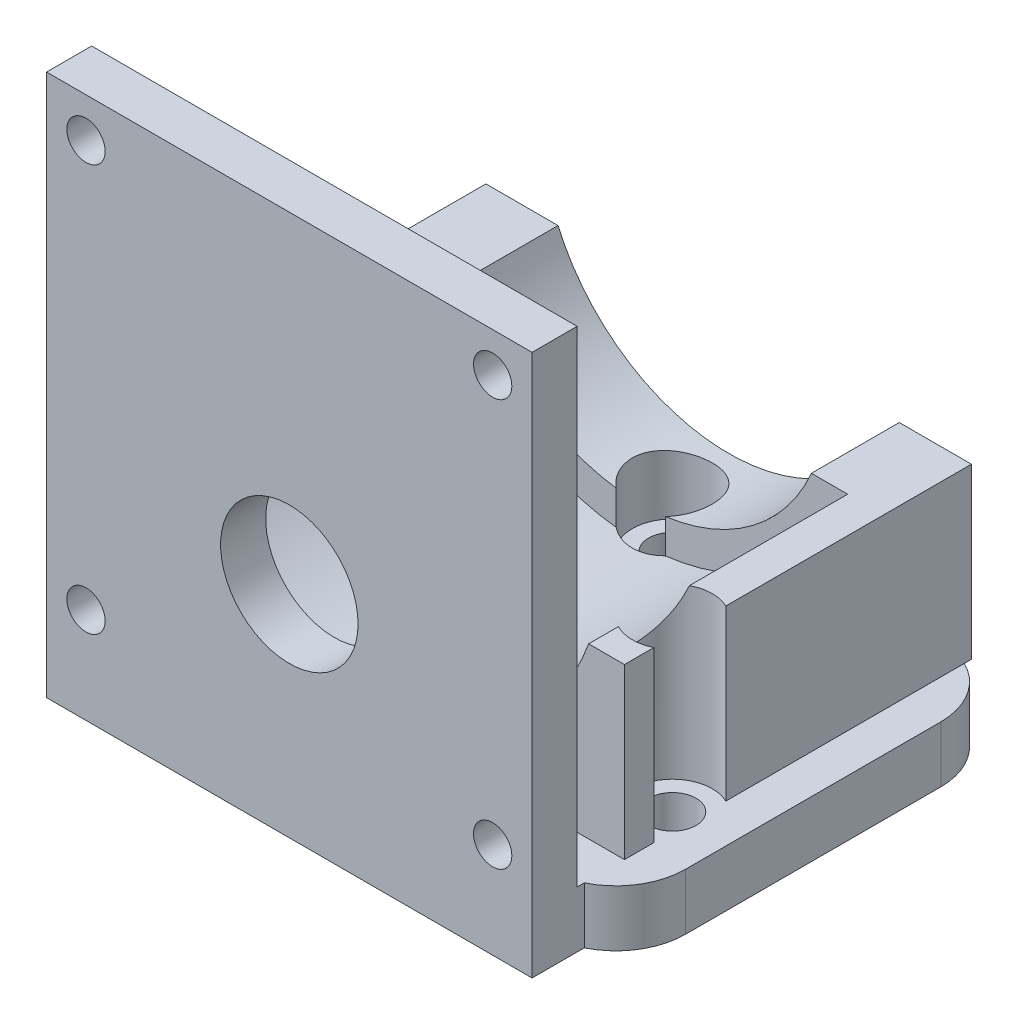
from build123d import *

# Parameters (mm, degrees)
SKETCH_1_W          = 30
SKETCH_1_H          = 30
EXTRUDE_1_DEPTH     = 5
SKETCH_2_W          = 30
SKETCH_2_H          = 5
EXTRUDE_2_DEPTH     = 10
SKETCH_3_R          = 2.1
CUT_EXTRUDE_1_DEPTH = 5
EXTRUDE_3_DEPTH     = 20
SKETCH_5_W          = 35
SKETCH_5_H          = 5
EXTRUDE_4_DEPTH     = 10
SKETCH_6_W          = 35
SKETCH_6_H          = 5
EXTRUDE_5_DEPTH     = 10
SKETCH_7_R          = 2.1
CUT_EXTRUDE_2_DEPTH = 10
FILLET_1_R          = 6.17
FILLET_2_R          = 6.17
SKETCH_8_W          = 43.093455854
SKETCH_8_H          = 31.755969384
CUT_EXTRUDE_3_DEPTH = 25
SKETCH_9_W          = 43.1
SKETCH_9_H          = 43.1
SKETCH_9_R          = 6.1
SKETCH_9_R_2        = 1.7
EXTRUDE_6_DEPTH     = 4
EXTRUDE_7_DEPTH     = 23
EXTRUDE_8_DEPTH     = 7.8
CUT_EXTRUDE_START   = -35
SKETCH_12_W         = 51.858978503
SKETCH_12_H         = 9.121001398
CUT_EXTRUDE_4_DEPTH = 35
SKETCH_14_W         = 43.1
SKETCH_14_H         = 5
EXTRUDE_9_DEPTH     = 8.2
SKETCH_15_R         = 2.1
CUT_EXTRUDE_5_DEPTH = 49.1
SKETCH_16_R         = 3.55
CUT_EXTRUDE_6_DEPTH = 44.1


with BuildPart() as part:
    # 스케치1 → 보스-돌출1 (new body)
    with BuildSketch(Plane.XY):
        Rectangle(SKETCH_1_W, SKETCH_1_H)
    extrude(amount=EXTRUDE_1_DEPTH)

    # 스케치2 → 보스-돌출2 (add)
    with BuildSketch(Plane(origin=(0, 0, 0), x_dir=(-1, 0, 0), z_dir=(0, 0, -1))):
        with Locations((0, -12.5)):
            Rectangle(SKETCH_2_W, SKETCH_2_H)
    extrude(amount=EXTRUDE_2_DEPTH)

    # 스케치3 → 컷-돌출1 (cut)
    with BuildSketch(Plane(origin=(0, -10, 0), x_dir=(1, 0, 0), z_dir=(0, 1, 0))):
        with Locations((0, 5)):
            Circle(SKETCH_3_R)
    extrude(amount=-CUT_EXTRUDE_1_DEPTH, mode=Mode.SUBTRACT)

    # 스케치4 → 보스-돌출3 (add)
    with BuildSketch(Plane.XY.offset(5)):
        Polygon((10.2, -15), (15, -15), (15, 15), (-15, 15), (-15, -15), (-10.2, -15), (-10.2, -18.997175384), (10.2, -18.997175384), align=None)
    extrude(amount=EXTRUDE_3_DEPTH)

    # 스케치5 → 보스-돌출4 (add)
    with BuildSketch(Plane.ZY.offset(15)):
        with Locations((7.5, -12.5)):
            Rectangle(SKETCH_5_W, SKETCH_5_H)
    extrude(amount=EXTRUDE_4_DEPTH)

    # 스케치6 → 보스-돌출5 (add)
    with BuildSketch(Plane(origin=(15, 0, 0), x_dir=(0, 0, -1), z_dir=(1, 0, 0))):
        with Locations((-7.5, -12.5)):
            Rectangle(SKETCH_6_W, SKETCH_6_H)
    extrude(amount=EXTRUDE_5_DEPTH)

    # 스케치7 → 컷-돌출2 (cut)
    with BuildSketch(Plane(origin=(0, -10, 0), x_dir=(1, 0, 0), z_dir=(0, 1, 0))):
        with Locations((-20, -15)):
            Circle(SKETCH_7_R)
        with Locations((20, -15)):
            Circle(SKETCH_7_R)
    extrude(amount=-CUT_EXTRUDE_2_DEPTH, mode=Mode.SUBTRACT)

    # 필렛1
    fillet_1_edges = [part.edges().sort_by_distance(p)[0] for p in [
        (25, -12.5, 25),
    ]]
    fillet(fillet_1_edges, radius=FILLET_1_R)

    # 필렛2
    fillet_2_edges = [part.edges().sort_by_distance(p)[0] for p in [
        (25, -12.5, -10),
    ]]
    fillet(fillet_2_edges, radius=FILLET_2_R)

    # 스케치8 → 컷-돌출3 (cut)
    with BuildSketch(Plane(origin=(0, 15, 0), x_dir=(1, 0, 0), z_dir=(0, 1, 0))):
        with Locations((-0.577881592, -10.851708682)):
            Rectangle(SKETCH_8_W, SKETCH_8_H)
    extrude(amount=-CUT_EXTRUDE_3_DEPTH, mode=Mode.SUBTRACT)

    # 스케치12 → 컷-돌출4 (cut)
    with BuildSketch(Plane.XY.offset(25).offset(CUT_EXTRUDE_START)):
        with Locations((0.929489252, -19.560500699)):
            Rectangle(SKETCH_12_W, SKETCH_12_H)
    extrude(amount=CUT_EXTRUDE_4_DEPTH, mode=Mode.SUBTRACT)



with BuildPart() as body_2:
    # 스케치9 → 보스-돌출6 (new body)
    with BuildSketch(Plane.XY.offset(29)):
        with Locations((0, 11.55)):
            Rectangle(SKETCH_9_W, SKETCH_9_H)
        with Locations((0, 4.5)):
            Circle(SKETCH_9_R, mode=Mode.SUBTRACT)
        with Locations((18.05, 29.6)):
            Circle(SKETCH_9_R_2, mode=Mode.SUBTRACT)
        with Locations((18.05, -6.5)):
            Circle(SKETCH_9_R_2, mode=Mode.SUBTRACT)
        with Locations((-18.05, -6.5)):
            Circle(SKETCH_9_R_2, mode=Mode.SUBTRACT)
        with Locations((-18.05, 29.6)):
            Circle(SKETCH_9_R_2, mode=Mode.SUBTRACT)
    extrude(amount=-EXTRUDE_6_DEPTH)


with BuildPart() as body_3:
    # 스케치10 → 보스-돌출7 (new body)
    with BuildSketch(Plane(origin=(0, 0, 20.8), x_dir=(-1, 0, 0), z_dir=(0, 0, -1))):
        with BuildLine():
            Line((-21.55, 5), (-18.367022078, 5))
            ThreePointArc((-18.367022078, 5), (0, -7.95), (18.367022078, 5))
            Line((18.367022078, 5), (21.55, 5))
            Line((21.55, 5), (21.55, -10))
            Line((21.55, -10), (-21.55, -10))
            Line((-21.55, -10), (-21.55, 5))
        make_face()
    extrude(amount=EXTRUDE_7_DEPTH)

    # 스케치11 → 보스-돌출8 (add)
    with BuildSketch(Plane(origin=(0, 0, -2.2), x_dir=(-1, 0, 0), z_dir=(0, 0, -1))):
        with BuildLine():
            Line((-21.55, 5), (-15.144223321, 5))
            ThreePointArc((-15.144223321, 5), (0, -4.95), (15.144223321, 5))
            Line((15.144223321, 5), (21.55, 5))
            Line((21.55, 5), (21.55, -10))
            Line((21.55, -10), (-21.55, -10))
            Line((-21.55, -10), (-21.55, 5))
        make_face()
    extrude(amount=EXTRUDE_8_DEPTH)


with BuildPart() as part_1:
    add(part.part)

    add(body_2.part)  # 보스-돌출9 merges body 2

    add(body_3.part)  # 보스-돌출9 merges body 3
    # 스케치14 → 보스-돌출9 (add)
    with BuildSketch(Plane.XY.offset(29)):
        with Locations((0, -12.5)):
            Rectangle(SKETCH_14_W, SKETCH_14_H)
    extrude(amount=-EXTRUDE_9_DEPTH)

    # 스케치15 → 컷-돌출5 (cut, through all)
    with BuildSketch(Plane.XZ.offset(15)):
        with Locations((-20, 15)):
            Circle(SKETCH_15_R)
        with Locations((0, -5)):
            Circle(SKETCH_15_R)
        with Locations((20, 15)):
            Circle(SKETCH_15_R)
    extrude(amount=-CUT_EXTRUDE_5_DEPTH, mode=Mode.SUBTRACT)

    # 스케치16 → 컷-돌출6 (cut, through all)
    with BuildSketch(Plane(origin=(0, -10, 0), x_dir=(1, 0, 0), z_dir=(0, 1, 0))):
        with Locations((20, -15)):
            Circle(SKETCH_16_R)
        with Locations((0, 5)):
            Circle(SKETCH_16_R)
        with Locations((-20, -15)):
            Circle(SKETCH_16_R)
    extrude(amount=CUT_EXTRUDE_6_DEPTH, mode=Mode.SUBTRACT)


solid = part_1.part
